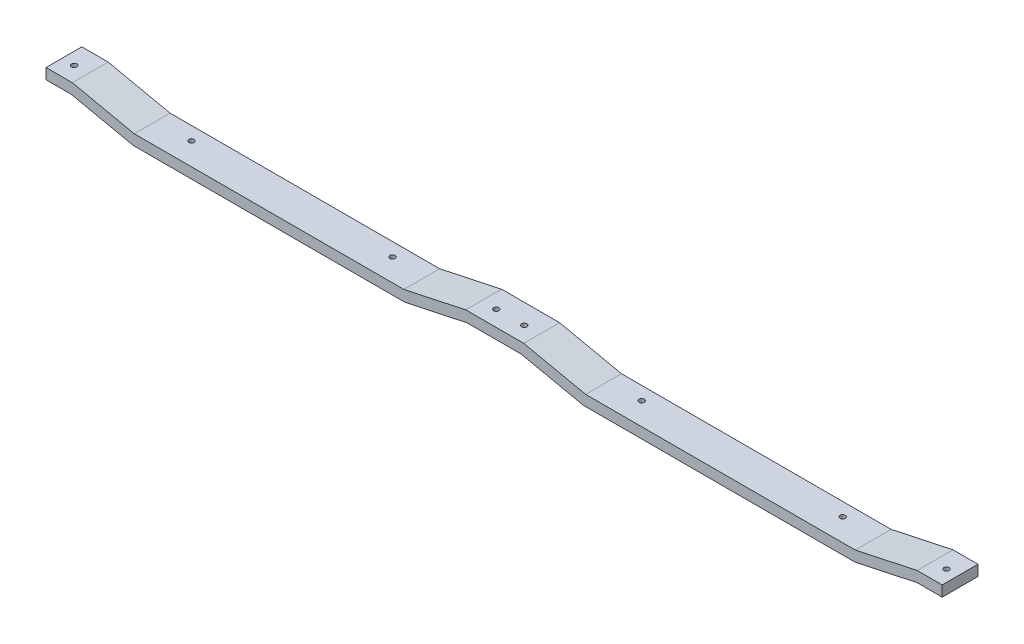
from build123d import *

# Parameters (mm, degrees)
BOSS_EXTRUDE1_DEPTH     = 6.75
SKETCH2_R               = 0.5
CUT_EXTRUDE1_DEPTH      = 3.5
CUT_EXTRUDE1_DEPTH_BACK = 3


with BuildPart() as part:
    # Sketch1 → Boss-Extrude1 (new body)
    with BuildSketch(Plane.XY):
        Polygon((37.296734757, 0.25), (47.546734757, 0.25), (59.223236254, -2.25), (110.463879182, -2.25), (122.14020427, 0.25), (126.893469513, 0.25), (126.893469513, 2.25), (122.178494939, 2.25), (110.502169851, -0.25), (59.684942458, -0.25), (48.00844096, 2.25), (37.085028553, 2.25), (25.408527056, -0.25), (-25.408700338, -0.25), (-37.085025426, 2.25), (-42.05, 2.25), (-42.05, 0.25), (-37.296734757, 0.25), (-25.620409669, -2.25), (25.620233259, -2.25), align=None)
    extrude(amount=BOSS_EXTRUDE1_DEPTH)

    # Sketch2 → Cut-Extrude1 (cut, two sides)
    with BuildSketch(Plane(origin=(0, -0.25, 0), x_dir=(1, 0, 0), z_dir=(0, 1, 0))) as cut_extrude1_sk:
        with Locations((45.113142199, -3.760486085)):
            Circle(SKETCH2_R)
        with Locations((65.993568392, -2.514696302)):
            Circle(SKETCH2_R)
        with Locations((103.888971043, -2.514696302)):
            Circle(SKETCH2_R)
        with Locations((124.713142199, -3.760486085)):
            Circle(SKETCH2_R)
        with Locations((39.863142199, -3.760486085)):
            Circle(SKETCH2_R)
        with Locations((-39.736857801, -3.760486085)):
            Circle(SKETCH2_R)
        with Locations((19.038971043, -2.514696302)):
            Circle(SKETCH2_R)
        with Locations((-18.856431608, -2.514696302)):
            Circle(SKETCH2_R)
    extrude(amount=CUT_EXTRUDE1_DEPTH, mode=Mode.SUBTRACT)
    extrude(cut_extrude1_sk.sketch, amount=-CUT_EXTRUDE1_DEPTH_BACK, mode=Mode.SUBTRACT)


solid = part.part
